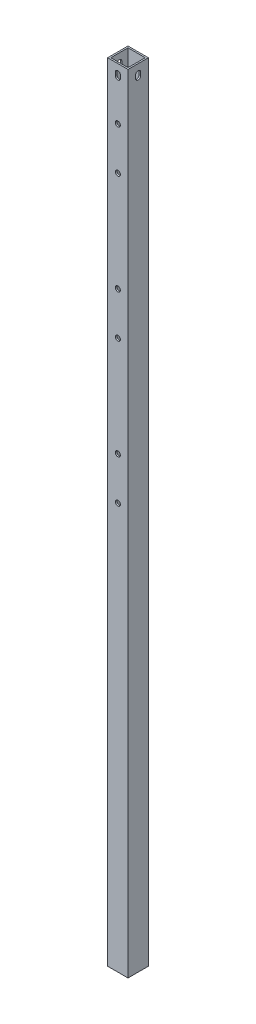
from build123d import *

# Parameters (mm, degrees)
SKETCH1_W           = 20
SKETCH1_H           = 20
SKETCH1_W_2         = 17
SKETCH1_H_2         = 17
BOSS_EXTRUDE1_DEPTH = 775.4
CUT_EXTRUDE1_DEPTH  = 5
SKETCH3_R           = 2.5
CUT_EXTRUDE8_DEPTH  = 5
CUT_EXTRUDE10_DEPTH = 101


with BuildPart() as part:
    # Sketch1 → Boss-Extrude1 (new body)
    with BuildSketch(Plane(origin=(0, 0, 0), x_dir=(1, 0, 0), z_dir=(0, 1, 0))):
        Rectangle(SKETCH1_W, SKETCH1_H)
        Rectangle(SKETCH1_W_2, SKETCH1_H_2, mode=Mode.SUBTRACT)
    extrude(amount=BOSS_EXTRUDE1_DEPTH)

    # Sketch2 → Cut-Extrude1 (cut)
    with BuildSketch(Plane.XY.offset(10)):
        with BuildLine():
            Line((-2.5, 766.9), (-2.5, 763.9))
            ThreePointArc((-2.5, 763.9), (0, 761.4), (2.5, 763.9))
            Line((2.5, 763.9), (2.5, 766.9))
            ThreePointArc((2.5, 766.9), (0, 769.4), (-2.5, 766.9))
        make_face()
    extrude(amount=-CUT_EXTRUDE1_DEPTH, mode=Mode.SUBTRACT)

    # Sketch3 → Cut-Extrude8 (cut)
    with BuildSketch(Plane.XY.offset(10)):
        with Locations((0, 723.9)):
            Circle(SKETCH3_R)
        with Locations((0, 681.9)):
            Circle(SKETCH3_R)
        with Locations((0, 583.1)):
            Circle(SKETCH3_R)
        with Locations((0, 541.1)):
            Circle(SKETCH3_R)
        with Locations((0, 442.3)):
            Circle(SKETCH3_R)
        with Locations((0, 400.3)):
            Circle(SKETCH3_R)
    extrude(amount=-CUT_EXTRUDE8_DEPTH, mode=Mode.SUBTRACT)

    # Sketch10 → Cut-Extrude10 (cut)
    with BuildSketch(Plane.ZY.offset(10)):
        with BuildLine():
            Line((-2.5, 766.9), (-2.5, 763.9))
            ThreePointArc((-2.5, 763.9), (0, 761.4), (2.5, 763.9))
            Line((2.5, 763.9), (2.5, 766.9))
            ThreePointArc((2.5, 766.9), (0, 769.4), (-2.5, 766.9))
        make_face()
    extrude(amount=-CUT_EXTRUDE10_DEPTH, mode=Mode.SUBTRACT)


solid = part.part
